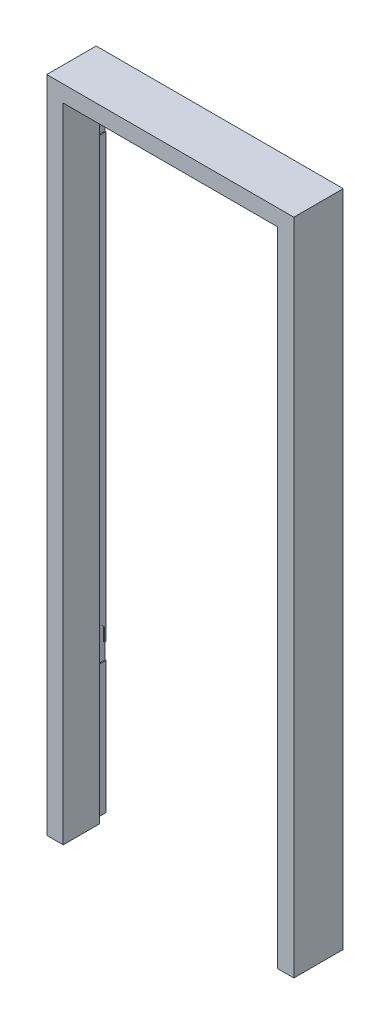
from build123d import *

# Parameters (mm, degrees)
BOSS_EXTRUDE1_DEPTH = 150
SKETCH4_W           = 690
SKETCH4_H           = 1970
CUT_EXTRUDE1_DEPTH  = 40
SKETCH5_W           = 30
SKETCH5_H           = 170
CUT_EXTRUDE2_DEPTH  = 5
CUT_EXTRUDE3_DEPTH  = 3


with BuildPart() as part:
    # Sketch1 → Boss-Extrude1 (new body)
    with BuildSketch(Plane.XY):
        Polygon((0, 0), (-750, 0), (-750, -2000), (-700, -2000), (-700, -50), (-50, -50), (-50, -2000), (0, -2000), align=None)
    extrude(amount=BOSS_EXTRUDE1_DEPTH)

    # Sketch4 → Cut-Extrude1 (cut)
    with BuildSketch(Plane(origin=(0, 0, 0), x_dir=(-1, 0, 0), z_dir=(0, 0, -1))):
        with Locations((375, -1015)):
            Rectangle(SKETCH4_W, SKETCH4_H)
    extrude(amount=-CUT_EXTRUDE1_DEPTH, mode=Mode.SUBTRACT)

    # Sketch5 → Cut-Extrude2 (cut)
    with BuildSketch(Plane.ZY.offset(30)):
        with Locations((20, -1045)):
            Rectangle(SKETCH5_W, SKETCH5_H)
    extrude(amount=-CUT_EXTRUDE2_DEPTH, mode=Mode.SUBTRACT)

    # Sketch6 → Cut-Extrude3 (cut)
    with BuildSketch(Plane(origin=(-720, 0, 0), x_dir=(0, 0, -1), z_dir=(1, 0, 0))):
        with BuildLine():
            Line((-35, -120), (-35, -210))
            Line((-35, -210), (0, -210))
            Line((0, -210), (0, -160))
            Line((0, -160), (-5, -160))
            Line((-5, -160), (-5, -120))
            ThreePointArc((-5, -120), (-20, -110), (-35, -120))
        make_face()
        with BuildLine():
            Line((-35, -1510), (-35, -1600))
            Line((-35, -1600), (0, -1600))
            Line((0, -1600), (0, -1550))
            Line((0, -1550), (-5, -1550))
            Line((-5, -1550), (-5, -1510))
            ThreePointArc((-5, -1510), (-20, -1500), (-35, -1510))
        make_face()
    extrude(amount=-CUT_EXTRUDE3_DEPTH, mode=Mode.SUBTRACT)


solid = part.part
